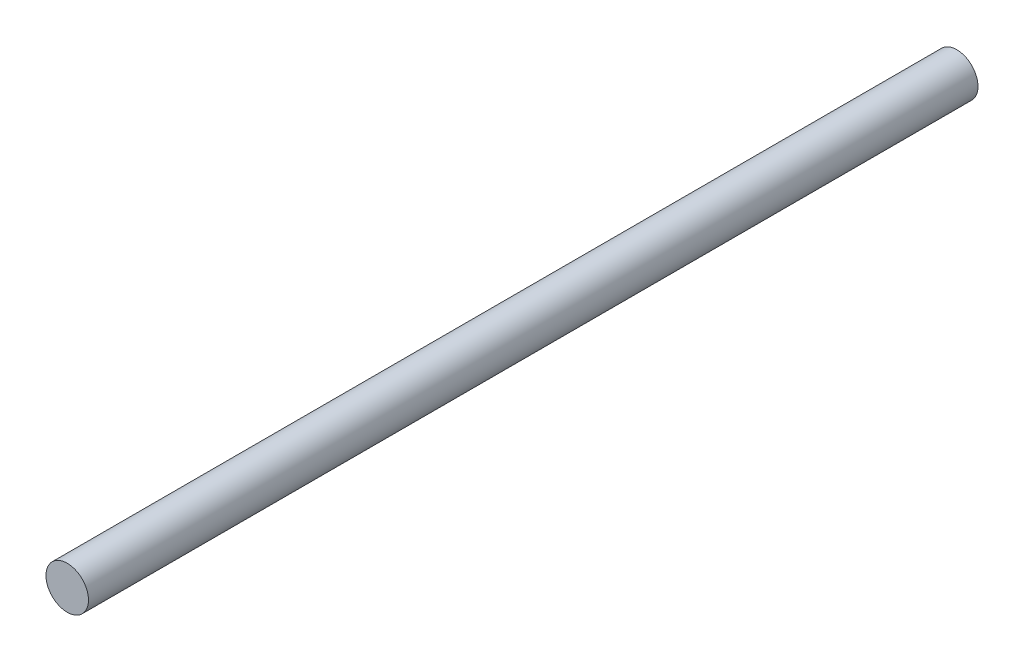
from build123d import *

# Parameters (mm, degrees)
SKETCH1_R           = 2.33
BOSS_EXTRUDE1_DEPTH = 97.5


with BuildPart() as part:
    # Sketch1 → Boss-Extrude1 (new body)
    with BuildSketch(Plane.XY):
        Circle(SKETCH1_R)
    extrude(amount=BOSS_EXTRUDE1_DEPTH)


solid = part.part
